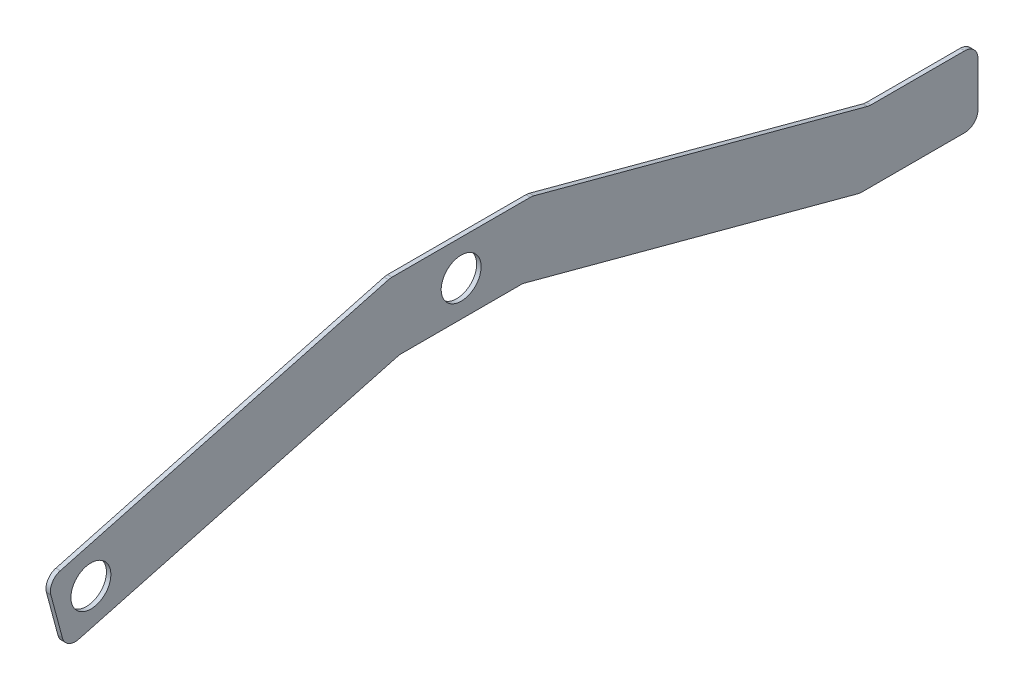
from build123d import *

# Parameters (mm, degrees)
SKETCH1_R           = 14.2875
BOSS_EXTRUDE1_DEPTH = 3.175
SKETCH3_R           = 12.7
CUT_EXTRUDE2_DEPTH  = 4.175
SKETCH5_W           = 50.8
SKETCH5_H           = 247.65
CUT_EXTRUDE4_DEPTH  = 4.175
SKETCH6_W           = 127
SKETCH6_H           = 25.4
CUT_EXTRUDE5_DEPTH  = 4.175
BOSS_EXTRUDE2_DEPTH = 3.175
FILLET1_R           = 9.525


with BuildPart() as part:
    # Sketch1 → Boss-Extrude1 (new body)
    with BuildSketch(Plane(origin=(0, 0, 0), x_dir=(0, 0, -1), z_dir=(1, 0, 0))):
        Polygon((-50.8, 25.4), (50.8, 25.4), (369.963359856, -60.119564527), (369.963359856, -337.700549698), (319.163359856, -337.700549698), (319.163359856, -99.099775516), (44.112053123, -25.4), (-44.112053123, -25.4), (-282.997152386, -89.409069432), (-296.145159877, -40.340037456), align=None)
        with Locations((-265.036640144, -58.300549698)):
            Circle(SKETCH1_R, mode=Mode.SUBTRACT)
        Circle(SKETCH1_R, mode=Mode.SUBTRACT)
    extrude(amount=BOSS_EXTRUDE1_DEPTH)

    # Sketch3 → Cut-Extrude2 (cut, through all)
    with BuildSketch(Plane(origin=(3.175, 0, 0), x_dir=(0, 0, -1), z_dir=(1, 0, 0))):
        with Locations((344.563359856, -312.300549698)):
            Circle(SKETCH3_R)
    extrude(amount=-CUT_EXTRUDE2_DEPTH, mode=Mode.SUBTRACT)

    # Sketch5 → Cut-Extrude4 (cut, through all)
    with BuildSketch(Plane(origin=(3.175, 0, 0), x_dir=(0, 0, -1), z_dir=(1, 0, 0))):
        with Locations((344.563359856, -213.875549698)):
            Rectangle(SKETCH5_W, SKETCH5_H)
    extrude(amount=-CUT_EXTRUDE4_DEPTH, mode=Mode.SUBTRACT)

    # Sketch6 → Cut-Extrude5 (cut, through all)
    with BuildSketch(Plane(origin=(3.175, 0, 0), x_dir=(0, 0, -1), z_dir=(1, 0, 0))):
        with Locations((306.463359856, -102.750549698)):
            Rectangle(SKETCH6_W, SKETCH6_H)
    extrude(amount=-CUT_EXTRUDE5_DEPTH, mode=Mode.SUBTRACT)

    # Sketch7 → Boss-Extrude2 (add)
    with BuildSketch(Plane(origin=(3.175, 0, 0), x_dir=(0, 0, -1), z_dir=(1, 0, 0))):
        Polygon((292.079136211, -39.250549698), (369.963359856, -39.250549698), (369.963359856, -60.119564527), align=None)
    extrude(amount=-BOSS_EXTRUDE2_DEPTH)

    # Fillet1
    fillet1_edges = [part.edges().sort_by_distance(p)[0] for p in [
        (1.5875, 25.4, 50.8),
        (1.5875, 25.4, -50.8),
        (1.5875, -25.4, -44.112053123),
        (1.5875, -25.4, 44.112053123),
        (1.5875, -89.409069432, 282.997152386),
        (1.5875, -40.340037456, 296.145159877),
        (1.5875, -90.050549698, -369.963359856),
        (1.5875, -90.050549698, -285.391189333),
        (1.5875, -39.250549698, -292.079136211),
        (1.5875, -39.250549698, -369.963359856),
    ]]
    fillet(fillet1_edges, radius=FILLET1_R)


solid = part.part
